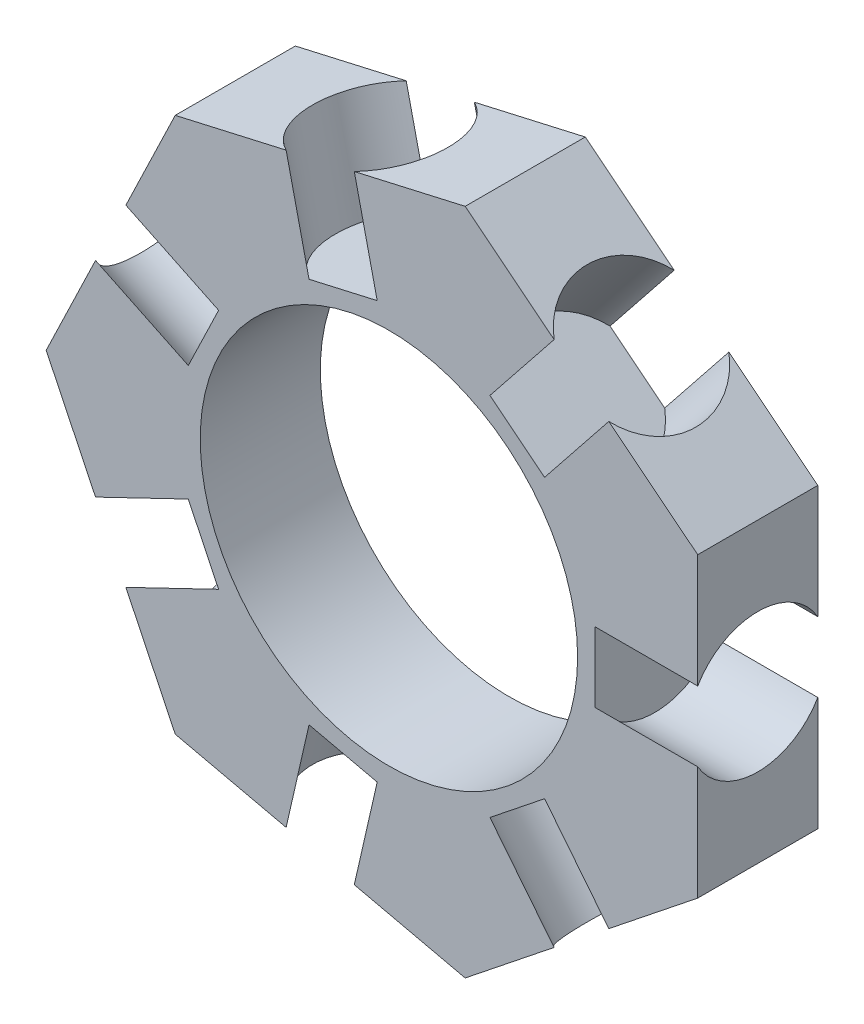
from build123d import *

# Parameters (mm, degrees)
SKETCH1_R           = 11
BOSS_EXTRUDE1_DEPTH = 3.5
SKETCH2_R           = 4.05
CUT_EXTRUDE3_DEPTH  = 6
CIRPATTERN1_COUNT   = 7


with BuildPart() as part:
    # Sketch1 → Boss-Extrude1 (new, symmetric)
    with BuildSketch(Plane.XY):
        Polygon((-19.978492755, 0), (-12.456386489, -15.619814608), (4.445632867, -19.47759023), (18, -8.668343139), (18, 8.668343139), (4.445632867, 19.47759023), (-12.456386489, 15.619814608), align=None)
        Circle(SKETCH1_R, mode=Mode.SUBTRACT)
    extrude(amount=BOSS_EXTRUDE1_DEPTH, both=True)

    # Sketch2 → Cut-Extrude3 (cut)
    with BuildSketch(Plane(origin=(0.058998969, -18.476369669, 0), x_dir=(-0.9749279121818237, 0.22252093395631425, 0), z_dir=(-0.22252093395631425, -0.9749279121818237, 0))):
        with Locations((4.168898776, 0)):
            Circle(SKETCH2_R)
    cut_extrude3 = extrude(amount=-CUT_EXTRUDE3_DEPTH, mode=Mode.SUBTRACT)

    # CirPattern1: Cut-Extrude3 ×7 about axis
    cirpattern1_axis = Axis((0, 0, 3.5), (0, 0, 1))
    for i in range(1, CIRPATTERN1_COUNT):
        add(cut_extrude3.rotate(cirpattern1_axis, i * 360 / CIRPATTERN1_COUNT), mode=Mode.SUBTRACT)


solid = part.part
